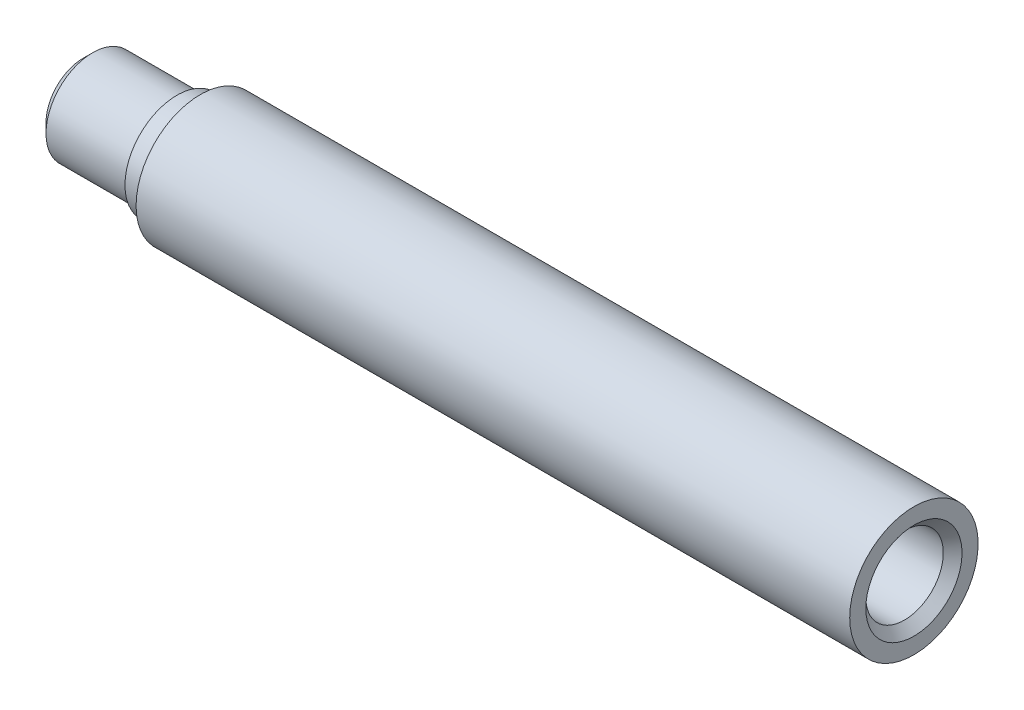
from build123d import *


with BuildPart() as part:
    # Sketch1 → Revolve1 (revolve)
    with BuildSketch(Plane(origin=(0, 0, 0), x_dir=(-1, 0, 0), z_dir=(0, 0, -1))):
        Polygon((-19, 3.311374294), (-17.010325592, 0), (36, 0), (36, 3.187874294), (35.2, 3.987874294), (28, 3.987874294), (28, 4.437874294), (26, 4.437874294), (26, 5.487874294), (-35, 5.487874294), (-35, 4.111374294), (-34.2, 3.311374294), align=None)
    revolve(axis=Axis((35, 0, 0), (-1, 0, 0)))


solid = part.part
